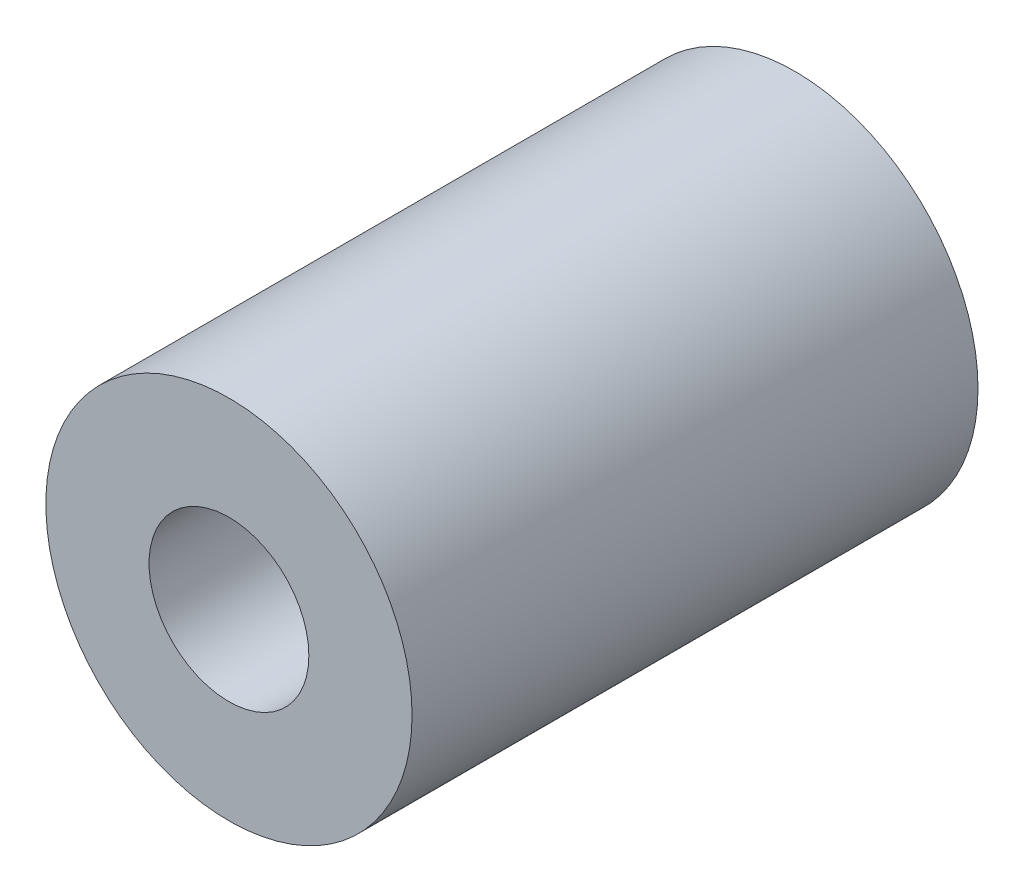
from build123d import *

# Parameters (mm, degrees)
SKETCH2_R           = 27.5
SKETCH2_R_2         = 12
BOSS_EXTRUDE1_DEPTH = 85


with BuildPart() as part:
    # Sketch2 → Boss-Extrude1 (new body)
    with BuildSketch(Plane.XY):
        Circle(SKETCH2_R)
        Circle(SKETCH2_R_2, mode=Mode.SUBTRACT)
    extrude(amount=BOSS_EXTRUDE1_DEPTH)


solid = part.part
